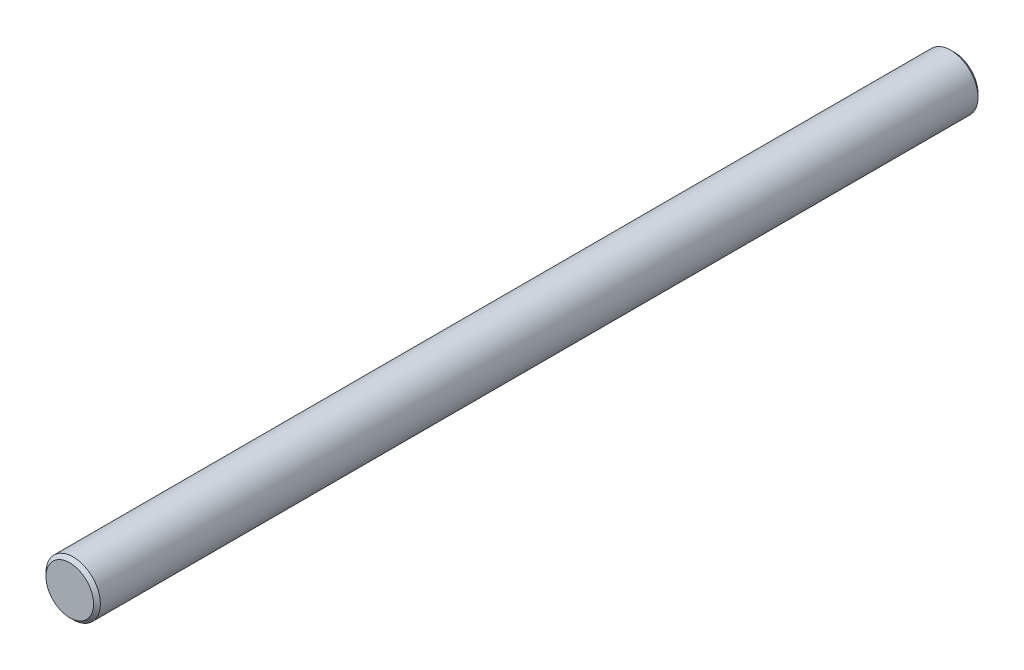
from build123d import *

# Parameters (mm, degrees)
SKETCH1_R           = 4
BOSS_EXTRUDE1_DEPTH = 130
CHAMFER1_SIZE       = 0.5


with BuildPart() as part:
    # Sketch1 → Boss-Extrude1 (new body)
    with BuildSketch(Plane.XY):
        Circle(SKETCH1_R)
    extrude(amount=BOSS_EXTRUDE1_DEPTH)

    # Chamfer1
    chamfer1_edges = [part.edges().sort_by_distance(p)[0] for p in [
        (-4, 0, 0),
        (-4, 0, 130),
    ]]
    chamfer(chamfer1_edges, length=CHAMFER1_SIZE)


solid = part.part
